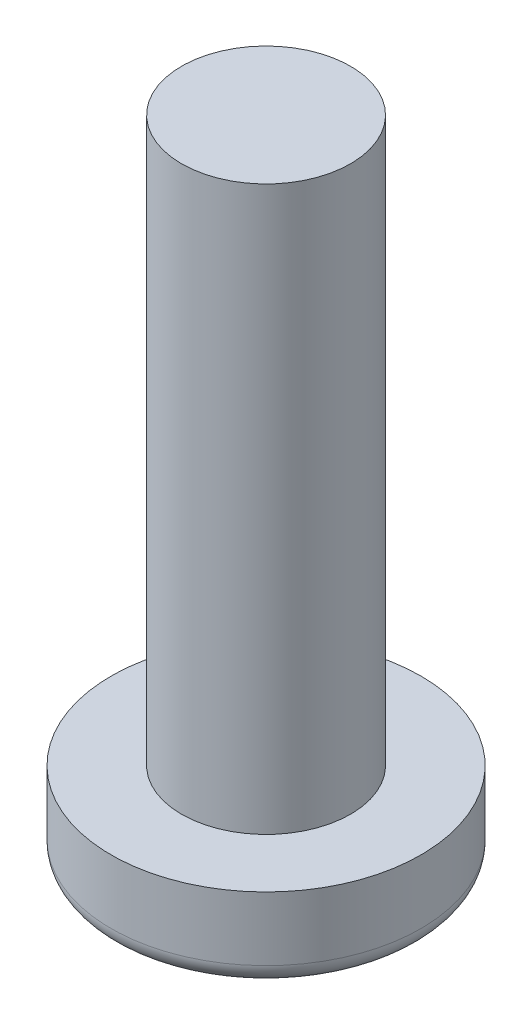
from build123d import *

# Parameters (mm, degrees)
SKETCH_1_W      = 2.75
SKETCH_1_H      = 1.5
SKETCH_2_R      = 1.5
EXTRUDE_1_DEPTH = 10
FILLET_1_R      = 0.367346939


with BuildPart() as part:
    # 草图1 → 旋转1 (revolve)
    with BuildSketch(Plane.XY):
        with Locations((1.375, 0.75)):
            Rectangle(SKETCH_1_W, SKETCH_1_H)
    revolve(axis=Axis((0, 1.5, 0), (0, -1, 0)))

    # 草图2 → 凸台-拉伸1 (add)
    with BuildSketch(Plane(origin=(0, 1.5, 0), x_dir=(-1, 0, 0), z_dir=(0, 1, 0))):
        Circle(SKETCH_2_R)
    extrude(amount=EXTRUDE_1_DEPTH)

    # 圆角1
    fillet_1_edges = [part.edges().sort_by_distance(p)[0] for p in [
        (-2.75, 0, 0),
    ]]
    fillet(fillet_1_edges, radius=FILLET_1_R)


solid = part.part
